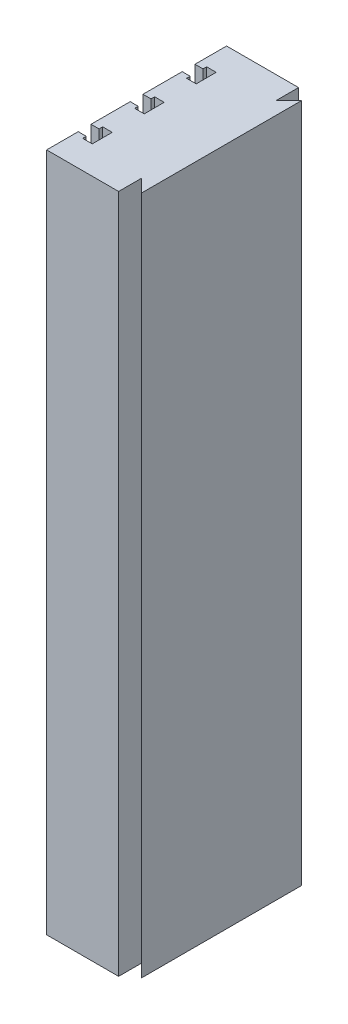
from build123d import *

# Parameters (mm, degrees)
BOSS_EXTRUDE1_DEPTH = 850
CUT_EXTRUDE1_DEPTH  = 22


with BuildPart() as part:
    # Sketch1 → Boss-Extrude1 (new body)
    with BuildSketch(Plane(origin=(0, 0, 0), x_dir=(1, 0, 0), z_dir=(0, 1, 0))):
        Polygon((-53, -73), (-53, -112.5), (37, -112.5), (37, -84), (53, -100), (53, 100), (37, 84), (37, 112.5), (-53, 112.5), (-53, 73), (-43, 73), (-43, 77.5), (-31, 77.5), (-31, 52.5), (-43, 52.5), (-43, 57), (-53, 57), (-53, 8), (-43, 8), (-43, 12.5), (-31, 12.5), (-31, -12.5), (-43, -12.5), (-43, -8), (-53, -8), (-53, -57), (-43, -57), (-43, -52.5), (-31, -52.5), (-31, -77.5), (-43, -77.5), (-43, -73), align=None)
    extrude(amount=BOSS_EXTRUDE1_DEPTH)

    # Sketch2 → Cut-Extrude1 (cut)
    with BuildSketch(Plane.ZY.offset(53)):
        with BuildLine():
            Line((-82.5, 65), (82.5, 65))
            ThreePointArc((82.5, 65), (102.5, 45), (82.5, 25))
            Line((82.5, 25), (-82.5, 25))
            ThreePointArc((-82.5, 25), (-102.5, 45), (-82.5, 65))
        make_face()
        with BuildLine():
            Line((-82.5, 785), (82.5, 785))
            ThreePointArc((82.5, 785), (102.5, 805), (82.5, 825))
            Line((82.5, 825), (-82.5, 825))
            ThreePointArc((-82.5, 825), (-102.5, 805), (-82.5, 785))
        make_face()
    extrude(amount=-CUT_EXTRUDE1_DEPTH, mode=Mode.SUBTRACT)


solid = part.part
